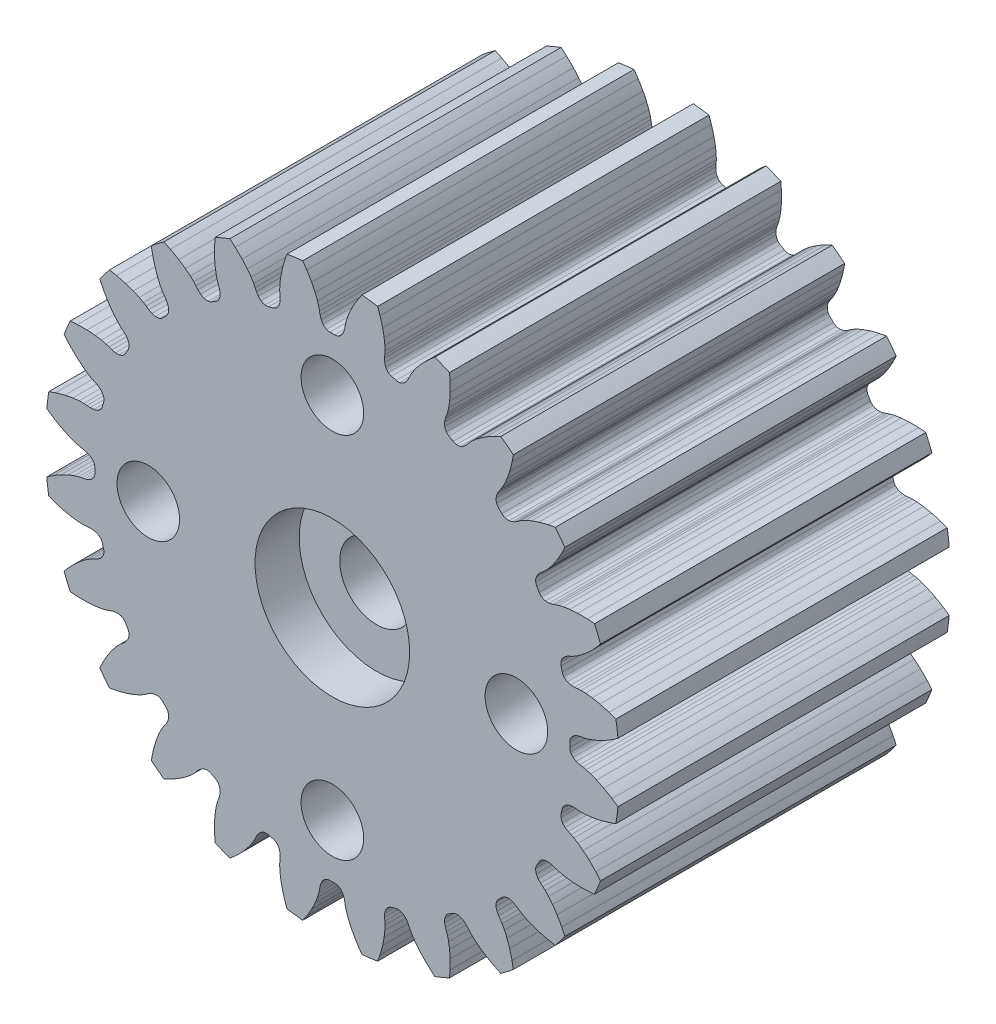
from build123d import *

# Parameters (mm, degrees)
SKETCH_357_R                                    = 7.800006142
F_0_6_14_4000MM_P_D_DEPTH                       = 4.5
CUT_EXTRUDE_20_DEPTH                            = 5.5
PATTERN_CIRCULAR_24_24_COUNT                    = 24
SKETCH3_R                                       = 0.85
SKETCH3_R_2                                     = 0.9
EXTRUDE3_DEPTH                                  = 10
CSK_FOR_M2_FLAT_HEAD_MACHINE_SCREW1_D           = 2
CSK_FOR_M2_FLAT_HEAD_MACHINE_SCREW1_CSINK_D     = 4.2
CSK_FOR_M2_FLAT_HEAD_MACHINE_SCREW1_CSINK_ANGLE = 90
SKETCH_1_R                                      = 2.1
CUT_EXTRUDE_1_DEPTH                             = 1.2


with BuildPart() as part:
    # Sketch 357 → 0.6 _ _ 14.4000mm P.D (new body, symmetric)
    with BuildSketch(Plane.XY):
        Circle(SKETCH_357_R)
    extrude(amount=F_0_6_14_4000MM_P_D_DEPTH, both=True)

    # 0.0000mm → Cut-Extrude 20 (cut, symmetric)
    with BuildSketch(Plane.XY):
        with BuildLine():
            ThreePointArc((-0.868944335, 7.844746726), (-0.779178648, 7.722195698), (-0.694389439, 7.596150377))
            ThreePointArc((-0.694389439, 7.596150377), (-0.62608147, 7.485297836), (-0.562263907, 7.371800773))
            ThreePointArc((-0.562263907, 7.371800773), (-0.512893268, 7.275176042), (-0.467427542, 7.176653625))
            ThreePointArc((-0.467427542, 7.176653625), (-0.434216468, 7.09645225), (-0.40423883, 7.014987061))
            ThreePointArc((-0.40423883, 7.014987061), (-0.384189922, 6.953046628), (-0.366631185, 6.890354789))
            ThreePointArc((-0.366631185, 6.890354789), (-0.356567547, 6.848134629), (-0.348193349, 6.805547171))
            ThreePointArc((-0.348193349, 6.805547171), (-0.341535054, 6.763011847), (-0.333023569, 6.720808276))
            ThreePointArc((-0.333023569, 6.720808276), (-0.32007047, 6.673439707), (-0.302915682, 6.627425824))
            ThreePointArc((-0.302915682, 6.627425824), (-0.280616301, 6.583362811), (-0.252481151, 6.542776794))
            ThreePointArc((-0.252481151, 6.542776794), (-0.209565552, 6.500433554), (-0.157955116, 6.469271692))
            ThreePointArc((-0.157955116, 6.469271692), (-0.112324668, 6.454727031), (-0.064698852, 6.449680579))
            ThreePointArc((-0.064698852, 6.449680579), (0, 6.450005079), (0.064698852, 6.449680579))
            ThreePointArc((0.064698852, 6.449680579), (0.112324668, 6.454727031), (0.157955116, 6.469271692))
            ThreePointArc((0.157955116, 6.469271692), (0.209565552, 6.500433554), (0.252481151, 6.542776794))
            ThreePointArc((0.252481151, 6.542776794), (0.280616301, 6.583362811), (0.302915682, 6.627425824))
            ThreePointArc((0.302915682, 6.627425824), (0.32007047, 6.673439707), (0.333023569, 6.720808276))
            ThreePointArc((0.333023569, 6.720808276), (0.341535054, 6.763011847), (0.348193349, 6.805547171))
            ThreePointArc((0.348193349, 6.805547171), (0.356567547, 6.848134629), (0.366631185, 6.890354789))
            ThreePointArc((0.366631185, 6.890354789), (0.384189922, 6.953046628), (0.40423883, 7.014987061))
            ThreePointArc((0.40423883, 7.014987061), (0.434216468, 7.09645225), (0.467427542, 7.176653625))
            ThreePointArc((0.467427542, 7.176653625), (0.512893268, 7.275176042), (0.562263907, 7.371800773))
            ThreePointArc((0.562263907, 7.371800773), (0.62608147, 7.485297836), (0.694389439, 7.596150377))
            ThreePointArc((0.694389439, 7.596150377), (0.779178648, 7.722195698), (0.868944335, 7.844746726))
            ThreePointArc((0.868944335, 7.844746726), (0, 7.892725477), (-0.868944335, 7.844746726))
        make_face()
    cut_extrude_20 = extrude(amount=CUT_EXTRUDE_20_DEPTH, both=True, mode=Mode.SUBTRACT)

    # Pattern Circular 24 _ 24: Cut-Extrude 20 ×24 about axis
    pattern_circular_24_24_axis = Axis((0, 0, 0), (0, 0, 1))
    for i in range(1, PATTERN_CIRCULAR_24_24_COUNT):
        add(cut_extrude_20.rotate(pattern_circular_24_24_axis, i * 360 / PATTERN_CIRCULAR_24_24_COUNT), mode=Mode.SUBTRACT)

    # Sketch3 → Extrude3 (cut, through all)
    with BuildSketch(Plane.XY.offset(4.5)):
        with Locations((0, -5)):
            Circle(SKETCH3_R)
        Circle(SKETCH3_R_2)
        with Locations((-5, 0)):
            Circle(SKETCH3_R)
        with Locations((0, 5)):
            Circle(SKETCH3_R)
        with Locations((5, 0)):
            Circle(SKETCH3_R)
    extrude(amount=-EXTRUDE3_DEPTH, mode=Mode.SUBTRACT)

    # CSK for M2 Flat Head Machine Screw1 (through all)
    with Locations(Plane.XY.offset(4.5)):
        with Locations((0, 0)):
            CounterSinkHole(CSK_FOR_M2_FLAT_HEAD_MACHINE_SCREW1_D / 2, CSK_FOR_M2_FLAT_HEAD_MACHINE_SCREW1_CSINK_D / 2, counter_sink_angle=CSK_FOR_M2_FLAT_HEAD_MACHINE_SCREW1_CSINK_ANGLE)

    # Sketch 1 → Cut-Extrude 1 (cut)
    with BuildSketch(Plane.XY.offset(4.5)):
        Circle(SKETCH_1_R)
    extrude(amount=-CUT_EXTRUDE_1_DEPTH, mode=Mode.SUBTRACT)


solid = part.part
